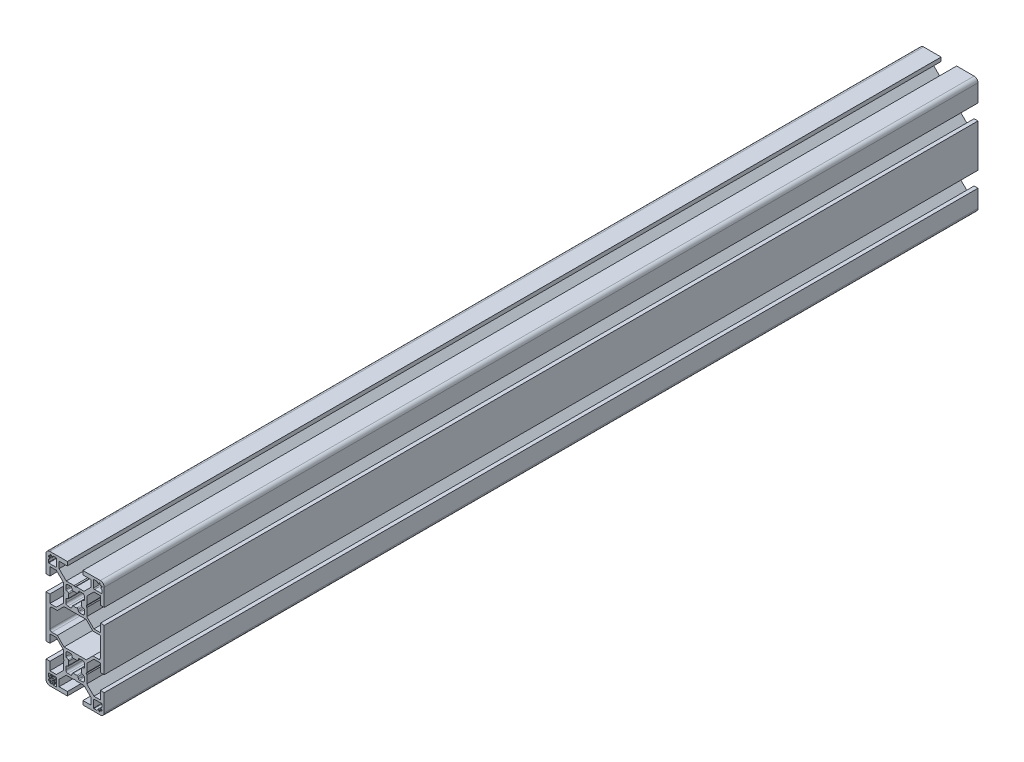
from build123d import *

# Parameters (mm, degrees)
EXTRUDE1_DEPTH = 450


with BuildPart() as part:
    # Sketch1 → Extrude1 (new body)
    with BuildSketch(Plane(origin=(0, 0, -450), x_dir=(-1, 0, 0), z_dir=(0, 0, -1))):
        with BuildLine():
            Line((9.664213562, -6.75), (13, -6.75))
            Line((13, -6.75), (13, -11))
            Line((13, -11), (15, -11))
            Line((15, -11), (15, 11))
            Line((15, 11), (13, 11))
            Line((13, 11), (13, 6.75))
            Line((13, 6.75), (9.664213562, 6.75))
            add(Edge.make_bspline(
                [(9.664213562, 6.75), (8.442809042, 7.971404521), (7.221404521, 9.192809042), (6, 10.414213562)],
                knots=[0, 0, 0, 0, 1, 1, 1, 1], degree=3))
            Line((6, 10.414213562), (6, 14.480384758))
            Line((6, 14.480384758), (5.7, 15))
            Line((5.7, 15), (6, 15.519615242))
            Line((6, 15.519615242), (6, 19.585786438))
            add(Edge.make_bspline(
                [(6, 19.585786438), (7.221404521, 20.807190958), (8.442809042, 22.028595479), (9.664213562, 23.25)],
                knots=[0, 0, 0, 0, 1, 1, 1, 1], degree=3))
            Line((9.664213562, 23.25), (13, 23.25))
            Line((13, 23.25), (13, 19))
            Line((13, 19), (15, 19))
            Line((15, 19), (15, 28))
            ThreePointArc((15, 28), (14.414213562, 29.414213562), (13, 30))
            Line((13, 30), (4, 30))
            Line((4, 30), (4, 28))
            Line((4, 28), (8.25, 28))
            Line((8.25, 28), (8.25, 24.664213562))
            add(Edge.make_bspline(
                [(8.25, 24.664213562), (7.028595479, 23.442809042), (5.807190958, 22.221404521), (4.585786438, 21)],
                knots=[0, 0, 0, 0, 1, 1, 1, 1], degree=3))
            Line((4.585786438, 21), (0.519615242, 21))
            Line((0.519615242, 21), (0, 20.7))
            Line((0, 20.7), (-0.519615242, 21))
            Line((-0.519615242, 21), (-4.585786438, 21))
            add(Edge.make_bspline(
                [(-4.585786438, 21), (-5.807190958, 22.221404521), (-7.028595479, 23.442809042), (-8.25, 24.664213562)],
                knots=[0, 0, 0, 0, 1, 1, 1, 1], degree=3))
            Line((-8.25, 24.664213562), (-8.25, 28))
            Line((-8.25, 28), (-4, 28))
            Line((-4, 28), (-4, 30))
            Line((-4, 30), (-13, 30))
            ThreePointArc((-13, 30), (-14.414213562, 29.414213562), (-15, 28))
            Line((-15, 28), (-15, 19))
            Line((-15, 19), (-13, 19))
            Line((-13, 19), (-13, 23.25))
            Line((-13, 23.25), (-9.664213562, 23.25))
            add(Edge.make_bspline(
                [(-9.664213562, 23.25), (-8.442809042, 22.028595479), (-7.221404521, 20.807190958), (-6, 19.585786438)],
                knots=[0, 0, 0, 0, 1, 1, 1, 1], degree=3))
            Line((-6, 19.585786438), (-6, 15.519615242))
            Line((-6, 15.519615242), (-5.7, 15))
            Line((-5.7, 15), (-6, 14.480384758))
            Line((-6, 14.480384758), (-6, 10.414213562))
            add(Edge.make_bspline(
                [(-6, 10.414213562), (-7.221404521, 9.192809042), (-8.442809042, 7.971404521), (-9.664213562, 6.75)],
                knots=[0, 0, 0, 0, 1, 1, 1, 1], degree=3))
            Line((-9.664213562, 6.75), (-13, 6.75))
            Line((-13, 6.75), (-13, 11))
            Line((-13, 11), (-15, 11))
            Line((-15, 11), (-15, -11))
            Line((-15, -11), (-13, -11))
            Line((-13, -11), (-13, -6.75))
            Line((-13, -6.75), (-9.664213562, -6.75))
            add(Edge.make_bspline(
                [(-9.664213562, -6.75), (-8.442809042, -7.971404521), (-7.221404521, -9.192809042), (-6, -10.414213562)],
                knots=[0, 0, 0, 0, 1, 1, 1, 1], degree=3))
            Line((-6, -10.414213562), (-6, -14.480384758))
            Line((-6, -14.480384758), (-5.7, -15))
            Line((-5.7, -15), (-6, -15.519615242))
            Line((-6, -15.519615242), (-6, -19.585786438))
            add(Edge.make_bspline(
                [(-6, -19.585786438), (-7.221404521, -20.807190958), (-8.442809042, -22.028595479), (-9.664213562, -23.25)],
                knots=[0, 0, 0, 0, 1, 1, 1, 1], degree=3))
            Line((-9.664213562, -23.25), (-13, -23.25))
            Line((-13, -23.25), (-13, -19))
            Line((-13, -19), (-15, -19))
            Line((-15, -19), (-15, -28))
            ThreePointArc((-15, -28), (-14.414213562, -29.414213562), (-13, -30))
            Line((-13, -30), (-4, -30))
            Line((-4, -30), (-4, -28))
            Line((-4, -28), (-8.25, -28))
            Line((-8.25, -28), (-8.25, -24.664213562))
            add(Edge.make_bspline(
                [(-8.25, -24.664213562), (-7.028595479, -23.442809042), (-5.807190958, -22.221404521), (-4.585786438, -21)],
                knots=[0, 0, 0, 0, 1, 1, 1, 1], degree=3))
            Line((-4.585786438, -21), (-0.519615242, -21))
            Line((-0.519615242, -21), (0, -20.7))
            Line((0, -20.7), (0.519615242, -21))
            Line((0.519615242, -21), (4.585786438, -21))
            add(Edge.make_bspline(
                [(4.585786438, -21), (5.807190958, -22.221404521), (7.028595479, -23.442809042), (8.25, -24.664213562)],
                knots=[0, 0, 0, 0, 1, 1, 1, 1], degree=3))
            Line((8.25, -24.664213562), (8.25, -28))
            Line((8.25, -28), (4, -28))
            Line((4, -28), (4, -30))
            Line((4, -30), (13, -30))
            ThreePointArc((13, -30), (14.414213562, -29.414213562), (15, -28))
            Line((15, -28), (15, -19))
            Line((15, -19), (13, -19))
            Line((13, -19), (13, -23.25))
            Line((13, -23.25), (9.664213562, -23.25))
            add(Edge.make_bspline(
                [(9.664213562, -23.25), (8.442809042, -22.028595479), (7.221404521, -20.807190958), (6, -19.585786438)],
                knots=[0, 0, 0, 0, 1, 1, 1, 1], degree=3))
            Line((6, -19.585786438), (6, -15.519615242))
            Line((6, -15.519615242), (5.7, -15))
            Line((5.7, -15), (6, -14.480384758))
            Line((6, -14.480384758), (6, -10.414213562))
            add(Edge.make_bspline(
                [(6, -10.414213562), (7.221404521, -9.192809042), (8.442809042, -7.971404521), (9.664213562, -6.75)],
                knots=[0, 0, 0, 0, 1, 1, 1, 1], degree=3))
        make_face()
        with BuildLine():
            Line((12.9, 28.5), (12.9, 28.2))
            ThreePointArc((12.9, 28.2), (12.987867966, 27.987867966), (13.2, 27.9))
            Line((13.2, 27.9), (13.5, 27.9))
            ThreePointArc((13.5, 27.9), (13.712132034, 27.812132034), (13.8, 27.6))
            Line((13.8, 27.6), (13.8, 27.4))
            ThreePointArc((13.8, 27.4), (13.741421356, 27.258578644), (13.6, 27.2))
            Line((13.6, 27.2), (13.43, 27.2))
            ThreePointArc((13.43, 27.2), (13.288578644, 27.141421356), (13.23, 27))
            Line((13.23, 27), (13.23, 26.6))
            ThreePointArc((13.23, 26.6), (13.288578644, 26.458578644), (13.43, 26.4))
            Line((13.43, 26.4), (13.6, 26.4))
            ThreePointArc((13.6, 26.4), (13.741421356, 26.341421356), (13.8, 26.2))
            Line((13.8, 26.2), (13.8, 24.7))
            ThreePointArc((13.8, 24.7), (13.741421356, 24.558578644), (13.6, 24.5))
            Line((13.6, 24.5), (10, 24.5))
            ThreePointArc((10, 24.5), (9.646446609, 24.646446609), (9.5, 25))
            Line((9.5, 25), (9.5, 28.6))
            ThreePointArc((9.5, 28.6), (9.558578644, 28.741421356), (9.7, 28.8))
            Line((9.7, 28.8), (11.2, 28.8))
            ThreePointArc((11.2, 28.8), (11.341421356, 28.741421356), (11.4, 28.6))
            Line((11.4, 28.6), (11.4, 28.43))
            ThreePointArc((11.4, 28.43), (11.458578644, 28.288578644), (11.6, 28.23))
            Line((11.6, 28.23), (12, 28.23))
            ThreePointArc((12, 28.23), (12.141421356, 28.288578644), (12.2, 28.43))
            Line((12.2, 28.43), (12.2, 28.6))
            ThreePointArc((12.2, 28.6), (12.258578644, 28.741421356), (12.4, 28.8))
            Line((12.4, 28.8), (12.6, 28.8))
            ThreePointArc((12.6, 28.8), (12.812132034, 28.712132034), (12.9, 28.5))
        make_face(mode=Mode.SUBTRACT)
        with BuildLine():
            Line((9.5, -28.6), (9.5, -25))
            ThreePointArc((9.5, -25), (9.646446609, -24.646446609), (10, -24.5))
            Line((10, -24.5), (13.6, -24.5))
            ThreePointArc((13.6, -24.5), (13.741421356, -24.558578644), (13.8, -24.7))
            Line((13.8, -24.7), (13.8, -26.2))
            ThreePointArc((13.8, -26.2), (13.741421356, -26.341421356), (13.6, -26.4))
            Line((13.6, -26.4), (13.43, -26.4))
            ThreePointArc((13.43, -26.4), (13.288578644, -26.458578644), (13.23, -26.6))
            Line((13.23, -26.6), (13.23, -27))
            ThreePointArc((13.23, -27), (13.288578644, -27.141421356), (13.43, -27.2))
            Line((13.43, -27.2), (13.6, -27.2))
            ThreePointArc((13.6, -27.2), (13.741421356, -27.258578644), (13.8, -27.4))
            Line((13.8, -27.4), (13.8, -27.6))
            ThreePointArc((13.8, -27.6), (13.712132034, -27.812132034), (13.5, -27.9))
            Line((13.5, -27.9), (13.2, -27.9))
            ThreePointArc((13.2, -27.9), (12.987867966, -27.987867966), (12.9, -28.2))
            Line((12.9, -28.2), (12.9, -28.5))
            ThreePointArc((12.9, -28.5), (12.812132034, -28.712132034), (12.6, -28.8))
            Line((12.6, -28.8), (12.4, -28.8))
            ThreePointArc((12.4, -28.8), (12.258578644, -28.741421356), (12.2, -28.6))
            Line((12.2, -28.6), (12.2, -28.43))
            ThreePointArc((12.2, -28.43), (12.141421356, -28.288578644), (12, -28.23))
            Line((12, -28.23), (11.6, -28.23))
            ThreePointArc((11.6, -28.23), (11.458578644, -28.288578644), (11.4, -28.43))
            Line((11.4, -28.43), (11.4, -28.6))
            ThreePointArc((11.4, -28.6), (11.341421356, -28.741421356), (11.2, -28.8))
            Line((11.2, -28.8), (9.7, -28.8))
            ThreePointArc((9.7, -28.8), (9.558578644, -28.741421356), (9.5, -28.6))
        make_face(mode=Mode.SUBTRACT)
        with BuildLine():
            Line((-5.717157288, 9), (5.717157288, 9))
            add(Edge.make_bspline(
                [(5.717157288, 9), (6.867157288, 7.85), (8.017157288, 6.7), (9.167157288, 5.55)],
                knots=[0, 0, 0, 0, 1, 1, 1, 1], degree=3))
            Line((9.167157288, 5.55), (12, 5.55))
            ThreePointArc((12, 5.55), (12.707106781, 5.257106781), (13, 4.55))
            Line((13, 4.55), (13, -4.55))
            ThreePointArc((13, -4.55), (12.707106781, -5.257106781), (12, -5.55))
            Line((12, -5.55), (9.167157288, -5.55))
            add(Edge.make_bspline(
                [(9.167157288, -5.55), (8.017157288, -6.7), (6.867157288, -7.85), (5.717157288, -9)],
                knots=[0, 0, 0, 0, 1, 1, 1, 1], degree=3))
            Line((5.717157288, -9), (-5.717157288, -9))
            add(Edge.make_bspline(
                [(-5.717157288, -9), (-6.867157288, -7.85), (-8.017157288, -6.7), (-9.167157288, -5.55)],
                knots=[0, 0, 0, 0, 1, 1, 1, 1], degree=3))
            Line((-9.167157288, -5.55), (-12, -5.55))
            ThreePointArc((-12, -5.55), (-12.707106781, -5.257106781), (-13, -4.55))
            Line((-13, -4.55), (-13, 5.55))
            Line((-13, 5.55), (-9.167157288, 5.55))
            add(Edge.make_bspline(
                [(-9.167157288, 5.55), (-8.017157288, 6.7), (-6.867157288, 7.85), (-5.717157288, 9)],
                knots=[0, 0, 0, 0, 1, 1, 1, 1], degree=3))
        make_face(mode=Mode.SUBTRACT)
        with BuildLine():
            Line((-11.2, 28.8), (-9.7, 28.8))
            ThreePointArc((-9.7, 28.8), (-9.558578644, 28.741421356), (-9.5, 28.6))
            Line((-9.5, 28.6), (-9.5, 25))
            ThreePointArc((-9.5, 25), (-9.646446609, 24.646446609), (-10, 24.5))
            Line((-10, 24.5), (-13.6, 24.5))
            ThreePointArc((-13.6, 24.5), (-13.741421356, 24.558578644), (-13.8, 24.7))
            Line((-13.8, 24.7), (-13.8, 26.2))
            ThreePointArc((-13.8, 26.2), (-13.741421356, 26.341421356), (-13.6, 26.4))
            Line((-13.6, 26.4), (-13.43, 26.4))
            ThreePointArc((-13.43, 26.4), (-13.288578644, 26.458578644), (-13.23, 26.6))
            Line((-13.23, 26.6), (-13.23, 27))
            ThreePointArc((-13.23, 27), (-13.288578644, 27.141421356), (-13.43, 27.2))
            Line((-13.43, 27.2), (-13.6, 27.2))
            ThreePointArc((-13.6, 27.2), (-13.741421356, 27.258578644), (-13.8, 27.4))
            Line((-13.8, 27.4), (-13.8, 27.6))
            ThreePointArc((-13.8, 27.6), (-13.712132034, 27.812132034), (-13.5, 27.9))
            Line((-13.5, 27.9), (-13.2, 27.9))
            ThreePointArc((-13.2, 27.9), (-12.987867966, 27.987867966), (-12.9, 28.2))
            Line((-12.9, 28.2), (-12.9, 28.5))
            ThreePointArc((-12.9, 28.5), (-12.812132034, 28.712132034), (-12.6, 28.8))
            Line((-12.6, 28.8), (-12.4, 28.8))
            ThreePointArc((-12.4, 28.8), (-12.258578644, 28.741421356), (-12.2, 28.6))
            Line((-12.2, 28.6), (-12.2, 28.43))
            ThreePointArc((-12.2, 28.43), (-12.141421356, 28.288578644), (-12, 28.23))
            Line((-12, 28.23), (-11.6, 28.23))
            ThreePointArc((-11.6, 28.23), (-11.458578644, 28.288578644), (-11.4, 28.43))
            Line((-11.4, 28.43), (-11.4, 28.6))
            ThreePointArc((-11.4, 28.6), (-11.341421356, 28.741421356), (-11.2, 28.8))
        make_face(mode=Mode.SUBTRACT)
        with BuildLine():
            Line((-13.8, -26.2), (-13.8, -24.7))
            ThreePointArc((-13.8, -24.7), (-13.741421356, -24.558578644), (-13.6, -24.5))
            Line((-13.6, -24.5), (-10, -24.5))
            ThreePointArc((-10, -24.5), (-9.646446609, -24.646446609), (-9.5, -25))
            Line((-9.5, -25), (-9.5, -28.6))
            ThreePointArc((-9.5, -28.6), (-9.558578644, -28.741421356), (-9.7, -28.8))
            Line((-9.7, -28.8), (-11.2, -28.8))
            ThreePointArc((-11.2, -28.8), (-11.341421356, -28.741421356), (-11.4, -28.6))
            Line((-11.4, -28.6), (-11.4, -28.43))
            ThreePointArc((-11.4, -28.43), (-11.458578644, -28.288578644), (-11.6, -28.23))
            Line((-11.6, -28.23), (-12, -28.23))
            ThreePointArc((-12, -28.23), (-12.141421356, -28.288578644), (-12.2, -28.43))
            Line((-12.2, -28.43), (-12.2, -28.6))
            ThreePointArc((-12.2, -28.6), (-12.258578644, -28.741421356), (-12.4, -28.8))
            Line((-12.4, -28.8), (-12.6, -28.8))
            ThreePointArc((-12.6, -28.8), (-12.812132034, -28.712132034), (-12.9, -28.5))
            Line((-12.9, -28.5), (-12.9, -28.2))
            ThreePointArc((-12.9, -28.2), (-12.987867966, -27.987867966), (-13.2, -27.9))
            Line((-13.2, -27.9), (-13.5, -27.9))
            ThreePointArc((-13.5, -27.9), (-13.712132034, -27.812132034), (-13.8, -27.6))
            Line((-13.8, -27.6), (-13.8, -27.4))
            ThreePointArc((-13.8, -27.4), (-13.741421356, -27.258578644), (-13.6, -27.2))
            Line((-13.6, -27.2), (-13.43, -27.2))
            ThreePointArc((-13.43, -27.2), (-13.288578644, -27.141421356), (-13.23, -27))
            Line((-13.23, -27), (-13.23, -26.6))
            ThreePointArc((-13.23, -26.6), (-13.288578644, -26.458578644), (-13.43, -26.4))
            Line((-13.43, -26.4), (-13.6, -26.4))
            ThreePointArc((-13.6, -26.4), (-13.741421356, -26.341421356), (-13.8, -26.2))
        make_face(mode=Mode.SUBTRACT)
        with BuildLine():
            Line((4.8, 18.8), (4.8, 17.231208165))
            ThreePointArc((4.8, 17.231208165), (4.713294875, 16.949805702), (4.483250613, 16.765999381))
            Line((4.483250613, 16.765999381), (3.598683883, 16.41755928))
            ThreePointArc((3.598683883, 16.41755928), (3.33715829, 16.180767059), (3.297071099, 15.830254278))
            ThreePointArc((3.297071099, 15.830254278), (3.4, 15), (3.297071099, 14.169745722))
            ThreePointArc((3.297071099, 14.169745722), (3.33715829, 13.819232941), (3.598683883, 13.58244072))
            Line((3.598683883, 13.58244072), (4.483250613, 13.234000619))
            ThreePointArc((4.483250613, 13.234000619), (4.713294875, 13.050194298), (4.8, 12.768791835))
            Line((4.8, 12.768791835), (4.8, 11.2))
            ThreePointArc((4.8, 11.2), (4.507106781, 10.492893219), (3.8, 10.2))
            Line((3.8, 10.2), (2.231208165, 10.2))
            ThreePointArc((2.231208165, 10.2), (1.949805702, 10.286705125), (1.765999381, 10.516749387))
            Line((1.765999381, 10.516749387), (1.41755928, 11.401316117))
            ThreePointArc((1.41755928, 11.401316117), (1.180767059, 11.66284171), (0.830254278, 11.702928901))
            ThreePointArc((0.830254278, 11.702928901), (0, 11.6), (-0.830254278, 11.702928901))
            ThreePointArc((-0.830254278, 11.702928901), (-1.180767059, 11.66284171), (-1.41755928, 11.401316117))
            Line((-1.41755928, 11.401316117), (-1.765999381, 10.516749387))
            ThreePointArc((-1.765999381, 10.516749387), (-1.949805702, 10.286705125), (-2.231208165, 10.2))
            Line((-2.231208165, 10.2), (-3.8, 10.2))
            ThreePointArc((-3.8, 10.2), (-4.507106781, 10.492893219), (-4.8, 11.2))
            Line((-4.8, 11.2), (-4.8, 12.768791835))
            ThreePointArc((-4.8, 12.768791835), (-4.713294875, 13.050194298), (-4.483250613, 13.234000619))
            Line((-4.483250613, 13.234000619), (-3.598683883, 13.58244072))
            ThreePointArc((-3.598683883, 13.58244072), (-3.33715829, 13.819232941), (-3.297071099, 14.169745722))
            ThreePointArc((-3.297071099, 14.169745722), (-3.4, 15), (-3.297071099, 15.830254278))
            ThreePointArc((-3.297071099, 15.830254278), (-3.33715829, 16.180767059), (-3.598683883, 16.41755928))
            Line((-3.598683883, 16.41755928), (-4.483250613, 16.765999381))
            ThreePointArc((-4.483250613, 16.765999381), (-4.713294875, 16.949805702), (-4.8, 17.231208165))
            Line((-4.8, 17.231208165), (-4.8, 18.8))
            ThreePointArc((-4.8, 18.8), (-4.507106781, 19.507106781), (-3.8, 19.8))
            Line((-3.8, 19.8), (-2.231208165, 19.8))
            ThreePointArc((-2.231208165, 19.8), (-1.949805702, 19.713294875), (-1.765999381, 19.483250613))
            add(Edge.make_bspline(
                [(-1.765999381, 19.483250613), (-1.649852839, 19.188395437), (-1.533706296, 18.893540261), (-1.417559753, 18.598685085)],
                knots=[0, 0, 0, 0, 1, 1, 1, 1], degree=3))
            ThreePointArc((-1.417559753, 18.598685085), (-1.180767633, 18.337158585), (-0.830254278, 18.297071099))
            ThreePointArc((-0.830254278, 18.297071099), (0, 18.4), (0.830254278, 18.297071099))
            ThreePointArc((0.830254278, 18.297071099), (1.180767059, 18.33715829), (1.41755928, 18.598683883))
            Line((1.41755928, 18.598683883), (1.765999381, 19.483250613))
            ThreePointArc((1.765999381, 19.483250613), (1.949805702, 19.713294875), (2.231208165, 19.8))
            Line((2.231208165, 19.8), (3.8, 19.8))
            ThreePointArc((3.8, 19.8), (4.507106781, 19.507106781), (4.8, 18.8))
        make_face(mode=Mode.SUBTRACT)
        with BuildLine():
            Line((4.8, -17.231208165), (4.8, -18.8))
            ThreePointArc((4.8, -18.8), (4.507106781, -19.507106781), (3.8, -19.8))
            Line((3.8, -19.8), (2.231208165, -19.8))
            ThreePointArc((2.231208165, -19.8), (1.949805702, -19.713294875), (1.765999381, -19.483250613))
            add(Edge.make_bspline(
                [(1.765999381, -19.483250613), (1.64985272, -19.188395137), (1.533706059, -18.89353966), (1.417559398, -18.598684183)],
                knots=[0, 0, 0, 0, 1, 1, 1, 1], degree=3))
            ThreePointArc((1.417559398, -18.598684183), (1.180767202, -18.337158363), (0.830254278, -18.297071099))
            ThreePointArc((0.830254278, -18.297071099), (0, -18.4), (-0.830254278, -18.297071099))
            ThreePointArc((-0.830254278, -18.297071099), (-1.180767059, -18.33715829), (-1.41755928, -18.598683883))
            Line((-1.41755928, -18.598683883), (-1.765999381, -19.483250613))
            ThreePointArc((-1.765999381, -19.483250613), (-1.949805702, -19.713294875), (-2.231208165, -19.8))
            Line((-2.231208165, -19.8), (-3.8, -19.8))
            ThreePointArc((-3.8, -19.8), (-4.507106781, -19.507106781), (-4.8, -18.8))
            Line((-4.8, -18.8), (-4.8, -17.231208165))
            ThreePointArc((-4.8, -17.231208165), (-4.713294875, -16.949805702), (-4.483250613, -16.765999381))
            Line((-4.483250613, -16.765999381), (-3.598683883, -16.41755928))
            ThreePointArc((-3.598683883, -16.41755928), (-3.33715829, -16.180767059), (-3.297071099, -15.830254278))
            ThreePointArc((-3.297071099, -15.830254278), (-3.4, -15), (-3.297071099, -14.169745722))
            ThreePointArc((-3.297071099, -14.169745722), (-3.33715829, -13.819232941), (-3.598683883, -13.58244072))
            Line((-3.598683883, -13.58244072), (-4.483250613, -13.234000619))
            ThreePointArc((-4.483250613, -13.234000619), (-4.713294875, -13.050194298), (-4.8, -12.768791835))
            Line((-4.8, -12.768791835), (-4.8, -11.2))
            ThreePointArc((-4.8, -11.2), (-4.507106781, -10.492893219), (-3.8, -10.2))
            Line((-3.8, -10.2), (-2.231208165, -10.2))
            ThreePointArc((-2.231208165, -10.2), (-1.949805702, -10.286705125), (-1.765999381, -10.516749387))
            Line((-1.765999381, -10.516749387), (-1.41755928, -11.401316117))
            ThreePointArc((-1.41755928, -11.401316117), (-1.180767059, -11.66284171), (-0.830254278, -11.702928901))
            ThreePointArc((-0.830254278, -11.702928901), (0, -11.6), (0.830254278, -11.702928901))
            ThreePointArc((0.830254278, -11.702928901), (1.180767059, -11.66284171), (1.41755928, -11.401316117))
            Line((1.41755928, -11.401316117), (1.765999381, -10.516749387))
            ThreePointArc((1.765999381, -10.516749387), (1.949805702, -10.286705125), (2.231208165, -10.2))
            Line((2.231208165, -10.2), (3.8, -10.2))
            ThreePointArc((3.8, -10.2), (4.507106781, -10.492893219), (4.8, -11.2))
            Line((4.8, -11.2), (4.8, -12.768791835))
            ThreePointArc((4.8, -12.768791835), (4.713294875, -13.050194298), (4.483250613, -13.234000619))
            Line((4.483250613, -13.234000619), (3.598683883, -13.58244072))
            ThreePointArc((3.598683883, -13.58244072), (3.33715829, -13.819232941), (3.297071099, -14.169745722))
            ThreePointArc((3.297071099, -14.169745722), (3.4, -15), (3.297071099, -15.830254278))
            ThreePointArc((3.297071099, -15.830254278), (3.33715829, -16.180767059), (3.598683883, -16.41755928))
            Line((3.598683883, -16.41755928), (4.483250613, -16.765999381))
            ThreePointArc((4.483250613, -16.765999381), (4.713294875, -16.949805702), (4.8, -17.231208165))
        make_face(mode=Mode.SUBTRACT)
    extrude(amount=-EXTRUDE1_DEPTH)


solid = part.part
